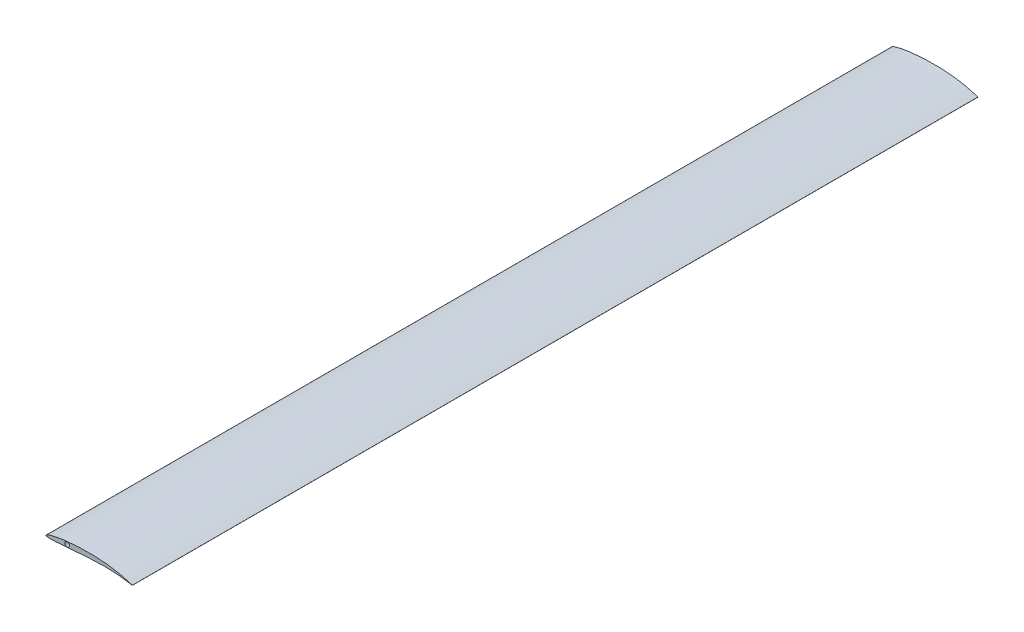
from build123d import *

# Parameters (mm, degrees)
SKETCH4_R           = 4.190569407
BOSS_EXTRUDE1_DEPTH = 1524


with BuildPart() as part:
    # Sketch4 → Boss-Extrude1 (new body)
    with BuildSketch(Plane.XY):
        with BuildLine():
            Line((155.702, 0.09809226), (155.702, -0.09809226))
            add(Edge.make_bspline(
                [(155.702, 0.09809226), (155.328455855, 0.21710942), (154.286379593, 0.549131644), (152.394434019, 1.135817898), (149.891446959, 1.887224122), (145.793800915, 3.065705429), (138.630182944, 4.968959508), (130.995988524, 6.68001387), (122.718135251, 8.23822641), (116.895890211, 9.166933244), (110.965655094, 9.937868735), (106.439374347, 10.435530424), (101.880030212, 10.843512829), (97.302362083, 11.161337519), (92.719325075, 11.376163119), (88.145375843, 11.529626054), (83.591973029, 11.636495982), (77.593716024, 11.710324659), (71.65833236, 11.685336347), (64.395545854, 11.52895988), (58.729451807, 11.30895133), (53.179849991, 10.992408761), (49.158789871, 10.713803162), (45.244594624, 10.393814748), (41.445202346, 10.034860451), (37.768282987, 9.639798138), (34.221312333, 9.211519042), (30.811527131, 8.75335647), (27.545989891, 8.268711541), (24.431555888, 7.761259757), (21.474930217, 7.234773828), (18.682626039, 6.693268182), (16.061024886, 6.140722414), (13.616351477, 5.581236837), (11.354657589, 5.018991745), (9.281890048, 4.458043189), (7.403813332, 3.902468458), (5.726033741, 3.356244159), (4.253966058, 2.823113628), (2.992645913, 2.306923182), (1.946754178, 1.8106852), (1.11946567, 1.338455793), (0.51241595, 0.888835226), (0.119562154, 0.462964377), (-0.04926786, 0.014201617), (0.10589775, -0.415412747), (0.520541366, -0.722853173), (1.129201705, -0.970029586), (1.957739862, -1.170098781), (3.002476487, -1.325609165), (4.263017798, -1.436906193), (5.734221446, -1.504788305), (7.411300699, -1.530452334), (9.288767614, -1.515333205), (11.36101404, -1.461084505), (13.62223909, -1.36966255), (16.066491709, -1.243097702), (18.687694771, -1.083738205), (21.479608446, -0.893954737), (24.43586128, -0.67648534), (27.549914466, -0.434035783), (30.815070608, -0.169587971), (34.224467498, 0.11376911), (37.771050722, 0.412820725), (41.447573159, 0.724258516), (45.246571387, 1.044721462), (49.160375079, 1.370674673), (53.181047287, 1.698756545), (58.731093411, 2.138916251), (65.871514228, 2.67438646), (73.134038571, 3.163637806), (79.06937037, 3.522547097), (83.590890156, 3.773842058), (88.144115441, 4.002163141), (92.717191906, 4.209610802), (97.298472859, 4.379203617), (101.87593735, 4.466645531), (106.434975089, 4.482287553), (110.961062663, 4.424004537), (116.884864026, 4.252534303), (124.077709927, 3.873607969), (132.343195007, 3.184789966), (138.866298944, 2.454100161), (143.705151457, 1.815614511), (146.96260774, 1.346522875), (149.88885512, 0.893212117), (152.392639903, 0.480978033), (154.285403175, 0.155019879), (155.328395834, -0.031338087), (155.702, -0.09809226)],
                knots=[0, 0, 0, 0, 0.003728993, 0.010402774, 0.018840568, 0.028585709, 0.050956865, 0.089334271, 0.10297657, 0.131071145, 0.145402462, 0.159853793, 0.174379924, 0.188939766, 0.203496108, 0.218017346, 0.232469302, 0.246817477, 0.275073667, 0.28892109, 0.315912882, 0.329003977, 0.341791348, 0.354250441, 0.366357575, 0.378089701, 0.389424235, 0.400339091, 0.410812773, 0.420824001, 0.430352033, 0.439376412, 0.447877061, 0.455834383, 0.463229144, 0.470042802, 0.476257372, 0.481856009, 0.486823221, 0.491145842, 0.494814445, 0.497826693, 0.500195359, 0.501969932, 0.50330007, 0.504508604, 0.506012742, 0.508062771, 0.510747122, 0.514093105, 0.518105083, 0.522777318, 0.528099107, 0.534056683, 0.540634481, 0.547815449, 0.555581622, 0.563914059, 0.572793129, 0.582198376, 0.592108707, 0.602502417, 0.613356987, 0.624649417, 0.636355909, 0.648451947, 0.660912408, 0.673711425, 0.68682217, 0.713868083, 0.741818751, 0.756056506, 0.770425669, 0.784891946, 0.799419294, 0.813967731, 0.828495783, 0.842964095, 0.857330143, 0.871547876, 0.89933031, 0.925831588, 0.950429236, 0.961757467, 0.972254714, 0.981731905, 0.989922338, 0.996390141, 1, 1, 1, 1], degree=3))
        make_face()
        with Locations((38.058872587, 5.051078985)):
            Circle(SKETCH4_R, mode=Mode.SUBTRACT)
    extrude(amount=BOSS_EXTRUDE1_DEPTH)


solid = part.part
